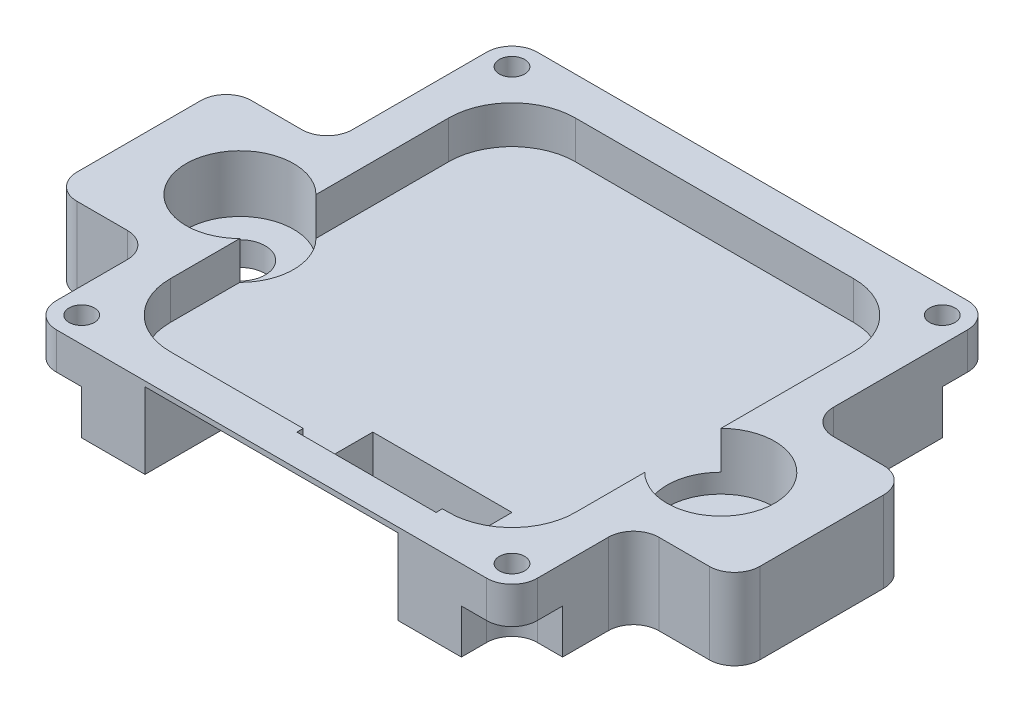
from build123d import *

# Parameters (mm, degrees)
SKETCH1_W           = 53.964084124
SKETCH1_H           = 13.786930342
SKETCH1_R           = 2
BOSS_EXTRUDE1_DEPTH = 6.4
SKETCH3_R           = 1
BOSS_EXTRUDE2_DEPTH = 6.4
SKETCH4_R           = 4.25
CUT_EXTRUDE1_DEPTH  = 4.5
SKETCH5_W           = 11
SKETCH5_H           = 6
CUT_EXTRUDE2_DEPTH  = 7.4
SKETCH6_W           = 32
SKETCH6_H           = 32
CUT_EXTRUDE3_DEPTH  = 3
FILLET2_R           = 2
FILLET3_R           = 5
CUT_EXTRUDE4_DEPTH  = 3.5
CUT_EXTRUDE5_DEPTH  = 10


with BuildPart() as part:
    # Sketch1 → Boss-Extrude1 (new body)
    with BuildSketch(Plane(origin=(0, 0, 0), x_dir=(1, 0, 0), z_dir=(0, 1, 0))):
        Rectangle(SKETCH1_W, SKETCH1_H)
        with Locations((-19, 0)):
            Circle(SKETCH1_R, mode=Mode.SUBTRACT)
        with Locations((19, 0)):
            Circle(SKETCH1_R, mode=Mode.SUBTRACT)
    extrude(amount=BOSS_EXTRUDE1_DEPTH)

    # Sketch3 → Boss-Extrude2 (add)
    with BuildSketch(Plane(origin=(0, 6.4, 0), x_dir=(1, 0, 0), z_dir=(0, 1, 0))):
        with BuildLine():
            Line((19, 2), (19, 21.5))
            Line((19, 21.5), (-19, 21.5))
            Line((-19, 21.5), (-19, 2))
            ThreePointArc((-19, 2), (-17, 0), (-19, -2))
            Line((-19, -2), (-19, -16.5))
            Line((-19, -16.5), (19, -16.5))
            Line((19, -16.5), (19, -2))
            ThreePointArc((19, -2), (17, 0), (19, 2))
        make_face()
        with Locations((-17, 19.5)):
            Circle(SKETCH3_R, mode=Mode.SUBTRACT)
        with Locations((17, 19.5)):
            Circle(SKETCH3_R, mode=Mode.SUBTRACT)
        with Locations((-17, -14.5)):
            Circle(SKETCH3_R, mode=Mode.SUBTRACT)
        with Locations((17, -14.5)):
            Circle(SKETCH3_R, mode=Mode.SUBTRACT)
    extrude(amount=-BOSS_EXTRUDE2_DEPTH)

    # Sketch4 → Cut-Extrude1 (cut)
    with BuildSketch(Plane(origin=(0, 6.4, 0), x_dir=(1, 0, 0), z_dir=(0, 1, 0))):
        with Locations((-19, 0)):
            Circle(SKETCH4_R)
        with Locations((19, 0)):
            Circle(SKETCH4_R)
    extrude(amount=-CUT_EXTRUDE1_DEPTH, mode=Mode.SUBTRACT)

    # Sketch5 → Cut-Extrude2 (cut, through all)
    with BuildSketch(Plane(origin=(0, 6.4, 0), x_dir=(1, 0, 0), z_dir=(0, 1, 0))):
        with Locations((5, -11)):
            Rectangle(SKETCH5_W, SKETCH5_H)
    extrude(amount=-CUT_EXTRUDE2_DEPTH, mode=Mode.SUBTRACT)

    # Sketch6 → Cut-Extrude3 (cut)
    with BuildSketch(Plane(origin=(0, 6.4, 0), x_dir=(1, 0, 0), z_dir=(0, 1, 0))):
        with Locations((0, 2.5)):
            Rectangle(SKETCH6_W, SKETCH6_H)
    extrude(amount=-CUT_EXTRUDE3_DEPTH, mode=Mode.SUBTRACT)

    # Fillet2
    fillet2_edges = [part.edges().sort_by_distance(p)[0] for p in [
        (-19, 3.2, 16.5),
        (19, 3.2, -21.5),
        (-19, 3.2, -21.5),
        (19, 3.2, -6.893465171),
        (19, 3.2, 6.893465171),
        (19, 3.2, 16.5),
        (-19, 3.2, 6.893465171),
        (-19, 3.2, -6.893465171),
        (26.982042062, 3.2, 6.893465171),
        (-26.982042062, 3.2, 6.893465171),
        (-26.982042062, 3.2, -6.893465171),
        (26.982042062, 3.2, -6.893465171),
    ]]
    fillet(fillet2_edges, radius=FILLET2_R)

    # Fillet3
    fillet3_edges = [part.edges().sort_by_distance(p)[0] for p in [
        (16, 4.9, -18.5),
        (-16, 4.9, 13.5),
        (16, 4.9, 13.5),
        (-16, 4.9, -18.5),
    ]]
    fillet(fillet3_edges, radius=FILLET3_R)

    # Sketch7 → Cut-Extrude4 (cut)
    with BuildSketch(Plane.XZ):
        with BuildLine():
            Line((-17, -17.5), (-19, -17.5))
            Line((-19, -17.5), (-19, -21.5))
            Line((-19, -21.5), (-15, -21.5))
            Line((-15, -21.5), (-15, -19.5))
            ThreePointArc((-15, -19.5), (-15.585786438, -18.085786438), (-17, -17.5))
        make_face()
        with BuildLine():
            Line((15, -19.5), (15, -21.5))
            Line((15, -21.5), (19, -21.5))
            Line((19, -21.5), (19, -17.5))
            Line((19, -17.5), (17, -17.5))
            ThreePointArc((17, -17.5), (15.585786438, -18.085786438), (15, -19.5))
        make_face()
        with BuildLine():
            Line((-17, 12.5), (-19, 12.5))
            Line((-19, 12.5), (-19, 16.5))
            Line((-19, 16.5), (-15, 16.5))
            Line((-15, 16.5), (-15, 14.5))
            ThreePointArc((-15, 14.5), (-15.585786438, 13.085786438), (-17, 12.5))
        make_face()
        with BuildLine():
            Line((17, 12.5), (19, 12.5))
            Line((19, 12.5), (19, 16.5))
            Line((19, 16.5), (15, 16.5))
            Line((15, 16.5), (15, 14.5))
            ThreePointArc((15, 14.5), (15.585786438, 13.085786438), (17, 12.5))
        make_face()
    extrude(amount=-CUT_EXTRUDE4_DEPTH, mode=Mode.SUBTRACT)

    # Sketch8 → Cut-Extrude5 (cut, symmetric)
    with BuildSketch(Plane(origin=(0, 0, 0), x_dir=(0, 0, -1), z_dir=(1, 0, 0))):
        Polygon((-10, 0), (-16.5, 6), (-16.5, 0), align=None)
    extrude(amount=CUT_EXTRUDE5_DEPTH, both=True, mode=Mode.SUBTRACT)


solid = part.part
